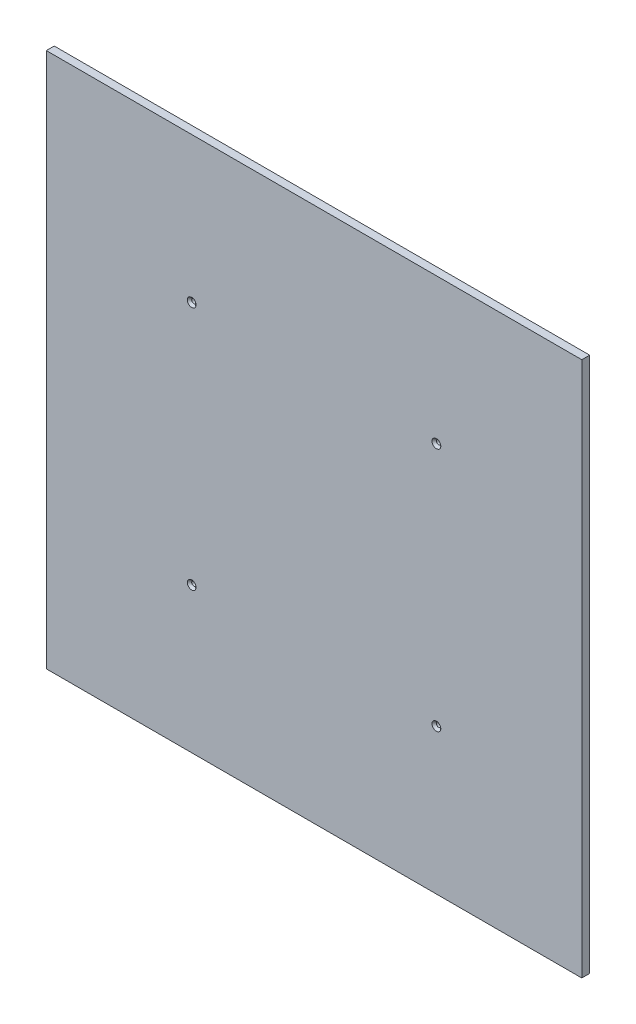
from build123d import *

# Parameters (mm, degrees)
BOSS_EXTRUDE1_START = 8
SKETCH1_W           = 1220
SKETCH1_H           = 1220
BOSS_EXTRUDE1_DEPTH = 18
SKETCH2_R           = 5
CUT_EXTRUDE1_DEPTH  = 19
CHAMFER1_SIZE       = 5


with BuildPart() as part:
    # Sketch1 → Boss-Extrude1 (new body)
    with BuildSketch(Plane.XY.offset(BOSS_EXTRUDE1_START)):
        Rectangle(SKETCH1_W, SKETCH1_H)
    extrude(amount=-BOSS_EXTRUDE1_DEPTH)

    # Sketch2 → Cut-Extrude1 (cut, through all)
    with BuildSketch(Plane(origin=(0, 0, -10), x_dir=(-1, 0, 0), z_dir=(0, 0, -1))):
        with Locations((-278.763455967, 278.763455967)):
            Circle(SKETCH2_R)
        with Locations((-278.763455967, -278.763455967)):
            Circle(SKETCH2_R)
        with Locations((278.763455967, -278.763455967)):
            Circle(SKETCH2_R)
        with Locations((278.763455967, 278.763455967)):
            Circle(SKETCH2_R)
    extrude(amount=-CUT_EXTRUDE1_DEPTH, mode=Mode.SUBTRACT)

    # Chamfer1
    chamfer1_edges = [part.edges().sort_by_distance(p)[0] for p in [
        (-273.763455967, 278.763455967, 8),
        (-273.763455967, -278.763455967, 8),
        (283.763455967, -278.763455967, 8),
        (283.763455967, 278.763455967, 8),
    ]]
    chamfer(chamfer1_edges, length=CHAMFER1_SIZE)


solid = part.part
